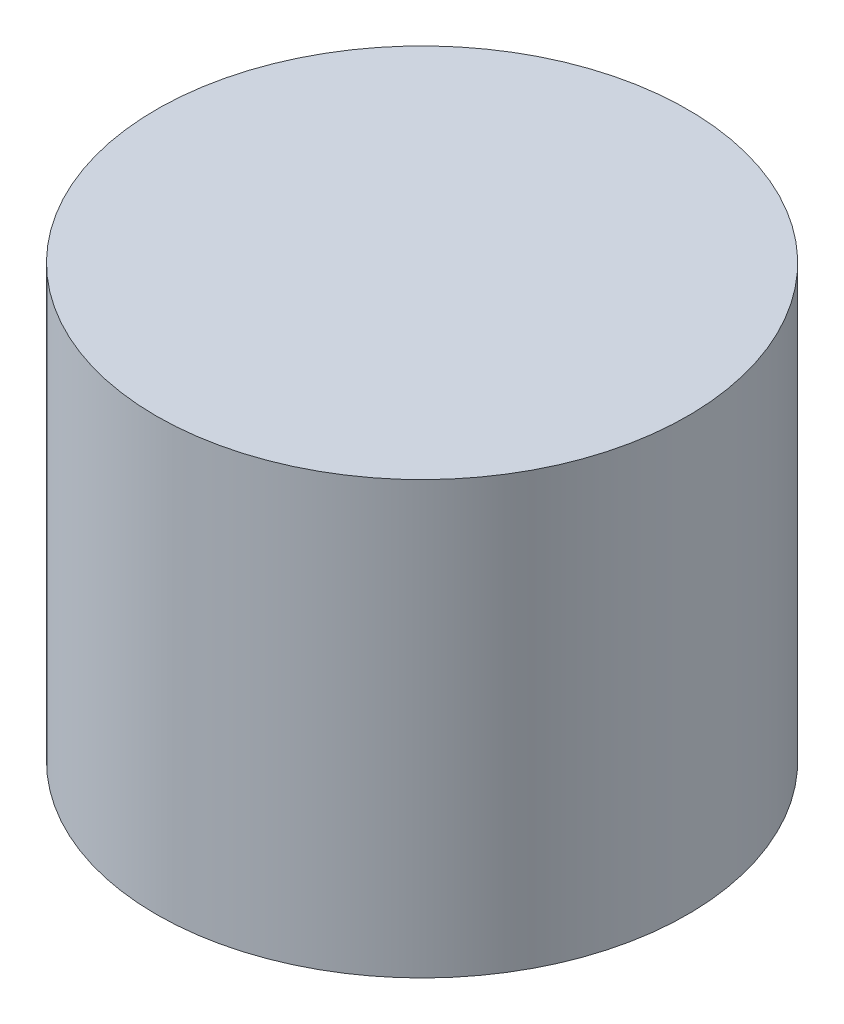
from build123d import *

# Parameters (mm, degrees)
SKETCH1_R                           = 50.8
BOSS_EXTRUDE1_DEPTH                 = 82.55
F_1_4_20_TAPPED_HOLE1_D             = 5.1054
F_1_4_20_TAPPED_HOLE1_DEPTH         = 19.05
F_1_4_20_TAPPED_HOLE1_TIP           = 1.533816902
F_5_32_0_15625_DIAMETER_HOLE1_D     = 3.96875
F_5_32_0_15625_DIAMETER_HOLE1_DEPTH = 5.08
F_5_32_0_15625_DIAMETER_HOLE1_TIP   = 1.192332791


with BuildPart() as part:
    # Sketch1 → Boss-Extrude1 (new body)
    with BuildSketch(Plane(origin=(0, 0, 0), x_dir=(1, 0, 0), z_dir=(0, 1, 0))):
        Circle(SKETCH1_R)
    extrude(amount=BOSS_EXTRUDE1_DEPTH)

    # 1/4-20 Tapped Hole1
    with Locations(Plane(origin=(0, 0, 0), x_dir=(-1, 0, 0), z_dir=(0, -1, 0))):
        with Locations((0, 0)):
            Hole(F_1_4_20_TAPPED_HOLE1_D / 2, depth=F_1_4_20_TAPPED_HOLE1_DEPTH)
            with Locations((0, 0, -(F_1_4_20_TAPPED_HOLE1_DEPTH + F_1_4_20_TAPPED_HOLE1_TIP / 2))):  # 118° drill point
                Cone(0, F_1_4_20_TAPPED_HOLE1_D / 2, F_1_4_20_TAPPED_HOLE1_TIP, mode=Mode.SUBTRACT)

    # 5/32 (0.15625) Diameter Hole1
    with Locations(Plane(origin=(0, 0, 0), x_dir=(-1, 0, 0), z_dir=(0, -1, 0))):
        with Locations((0, 44.45), (0, -44.45)):
            Hole(F_5_32_0_15625_DIAMETER_HOLE1_D / 2, depth=F_5_32_0_15625_DIAMETER_HOLE1_DEPTH)
            with Locations((0, 0, -(F_5_32_0_15625_DIAMETER_HOLE1_DEPTH + F_5_32_0_15625_DIAMETER_HOLE1_TIP / 2))):  # 118° drill point
                Cone(0, F_5_32_0_15625_DIAMETER_HOLE1_D / 2, F_5_32_0_15625_DIAMETER_HOLE1_TIP, mode=Mode.SUBTRACT)


solid = part.part
